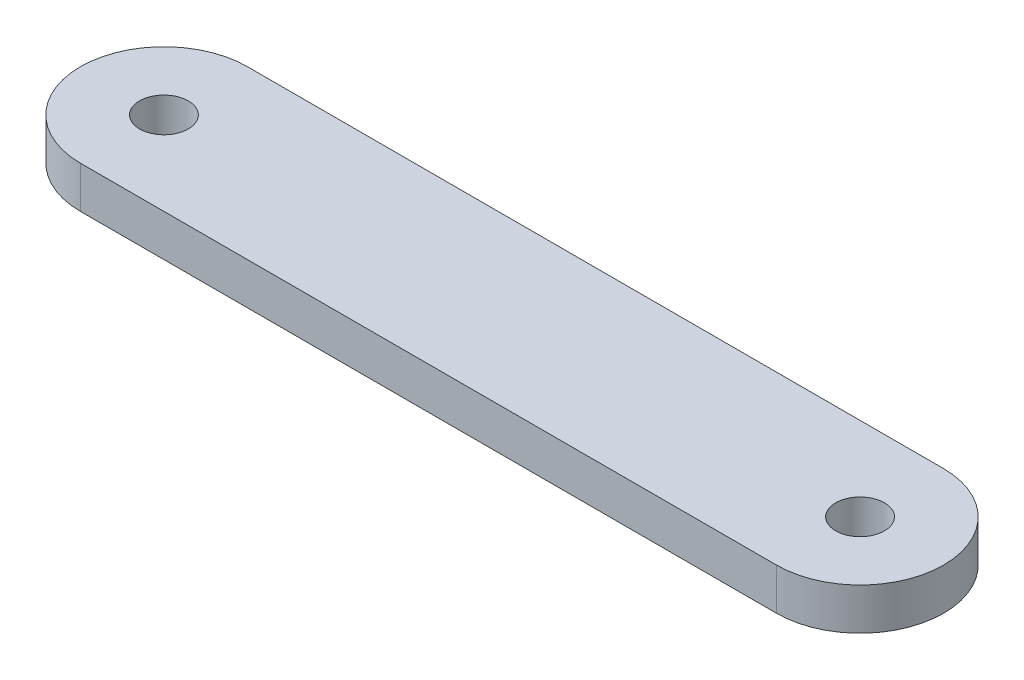
from build123d import *

# Parameters (mm, degrees)
SKETCH_1_R      = 1.75
EXTRUDE_1_DEPTH = 3


with BuildPart() as part:
    # 草圖1 → 填料-伸長1 (new body)
    with BuildSketch(Plane(origin=(0, 0, 0), x_dir=(1, 0, 0), z_dir=(0, 1, 0))):
        with BuildLine():
            Line((0, 6), (50, 6))
            ThreePointArc((50, 6), (56, 0), (50, -6))
            Line((50, -6), (0, -6))
            ThreePointArc((0, -6), (-6, 0), (0, 6))
        make_face()
        Circle(SKETCH_1_R, mode=Mode.SUBTRACT)
        with Locations((50, 0)):
            Circle(SKETCH_1_R, mode=Mode.SUBTRACT)
    extrude(amount=EXTRUDE_1_DEPTH)


solid = part.part
